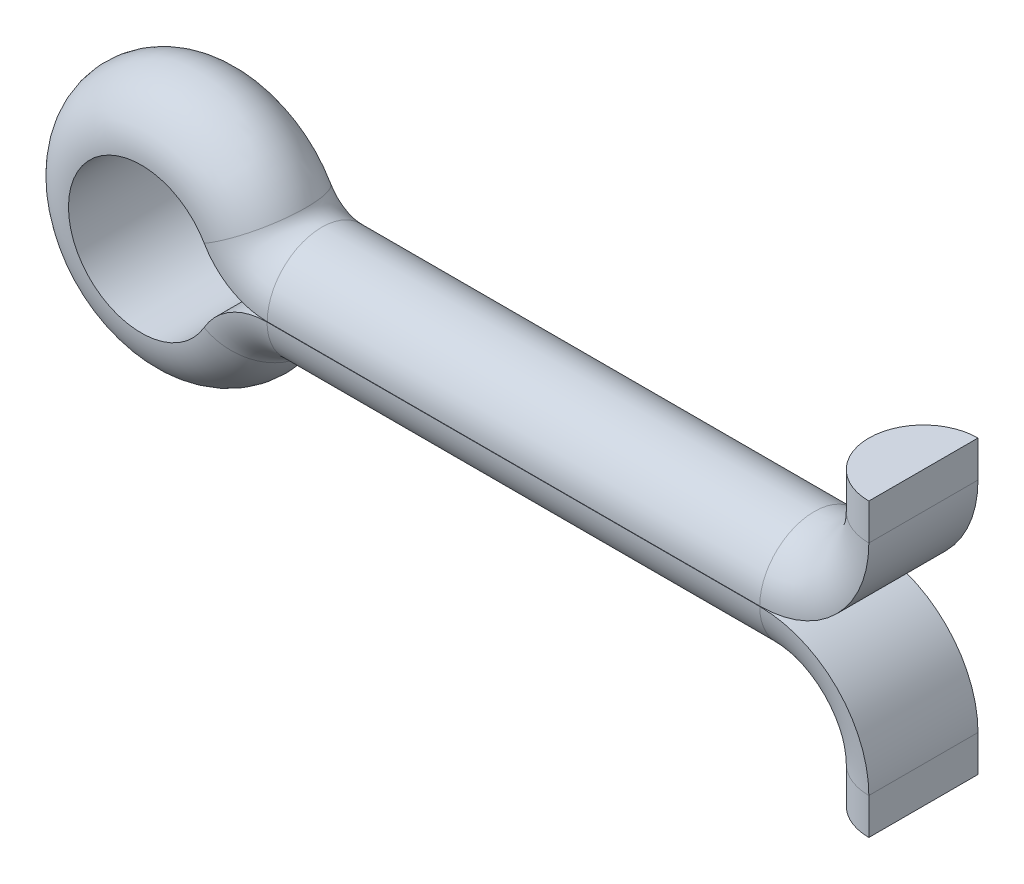
from build123d import *


with BuildPart() as part:
    # Sweep1: sweep along a path in Sketch1
    with BuildLine(Plane.XY) as sweep1_path:
        Line((20, 4), (20, 3))
        ThreePointArc((20, 3), (19.121320344, 0.878679656), (17, 0))
        Line((17, 0), (3.464101615, 0))
        ThreePointArc((3.464101615, 0), (2.464101615, 0.267949192), (1.732050808, 1))
        ThreePointArc((1.732050808, 1), (-1.999997913, 0.002889164), (1.729154418, -1.005))
        ThreePointArc((1.729154418, -1.005), (2.460811968, -0.276506418), (3.458308835, -0.01))
        Line((3.458308835, -0.01), (17, -0.01))
        ThreePointArc((17, -0.01), (19.121320344, -0.888679656), (20, -3.01))
        Line((20, -3.01), (20, -4.01))
    # Sketch3 → Sweep1 (sweep)
    with BuildSketch(Plane(origin=(20, 4, 0), x_dir=(1, 0, 0), z_dir=(0, 1, 0))):
        with BuildLine():
            Line((0, 1.5), (0, -1.5))
            ThreePointArc((0, -1.5), (-1.5, 0), (0, 1.5))
        make_face()
    sweep(path=sweep1_path.line)


solid = part.part
